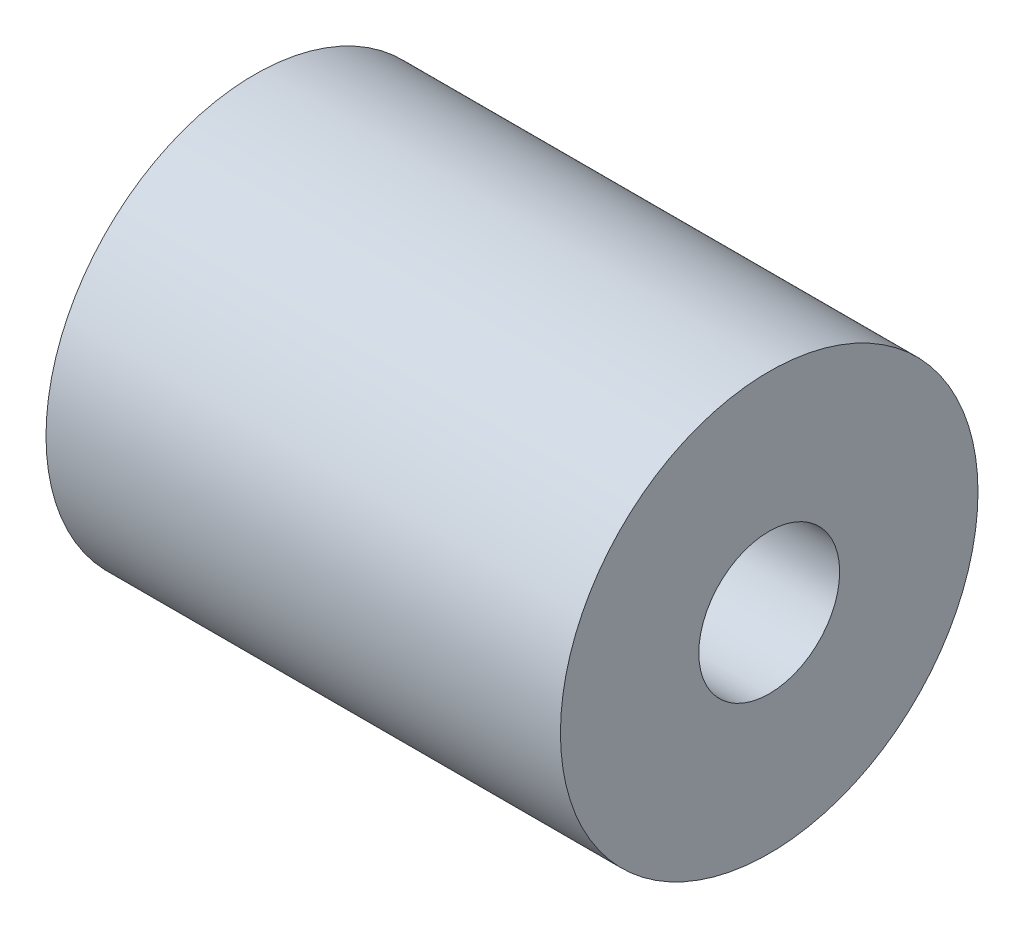
from build123d import *

# Parameters (mm, degrees)
EXTRUDE1_START              = -15.4
SKETCH1_R                   = 12.5
EXTRUDE1_DEPTH              = 30.8
F_3_8_24_TAPPED_HOLE3_D     = 8.4328
F_3_8_24_TAPPED_HOLE3_DEPTH = 15
F_3_8_24_TAPPED_HOLE3_TIP   = 2.533468714
F_3_8_24_TAPPED_HOLE4_D     = 8.4328
F_3_8_24_TAPPED_HOLE4_DEPTH = 18
F_3_8_24_TAPPED_HOLE4_TIP   = 2.533468714


with BuildPart() as part:
    # Sketch1 → Extrude1 (new body)
    with BuildSketch(Plane(origin=(0, 0, 0), x_dir=(0, 0, -1), z_dir=(1, 0, 0)).offset(EXTRUDE1_START)):
        Circle(SKETCH1_R)
    extrude(amount=EXTRUDE1_DEPTH)

    # 3_8-24 Tapped Hole3
    with Locations(Plane.ZY.offset(15.4)):
        with Locations((0, 0)):
            Hole(F_3_8_24_TAPPED_HOLE3_D / 2, depth=F_3_8_24_TAPPED_HOLE3_DEPTH)
            with Locations((0, 0, -(F_3_8_24_TAPPED_HOLE3_DEPTH + F_3_8_24_TAPPED_HOLE3_TIP / 2))):  # 118° drill point
                Cone(0, F_3_8_24_TAPPED_HOLE3_D / 2, F_3_8_24_TAPPED_HOLE3_TIP, mode=Mode.SUBTRACT)

    # 3_8-24 Tapped Hole4
    with Locations(Plane(origin=(15.4, 0, 0), x_dir=(0, 0, -1), z_dir=(1, 0, 0))):
        with Locations((0, 0)):
            Hole(F_3_8_24_TAPPED_HOLE4_D / 2, depth=F_3_8_24_TAPPED_HOLE4_DEPTH)
            with Locations((0, 0, -(F_3_8_24_TAPPED_HOLE4_DEPTH + F_3_8_24_TAPPED_HOLE4_TIP / 2))):  # 118° drill point
                Cone(0, F_3_8_24_TAPPED_HOLE4_D / 2, F_3_8_24_TAPPED_HOLE4_TIP, mode=Mode.SUBTRACT)


solid = part.part
